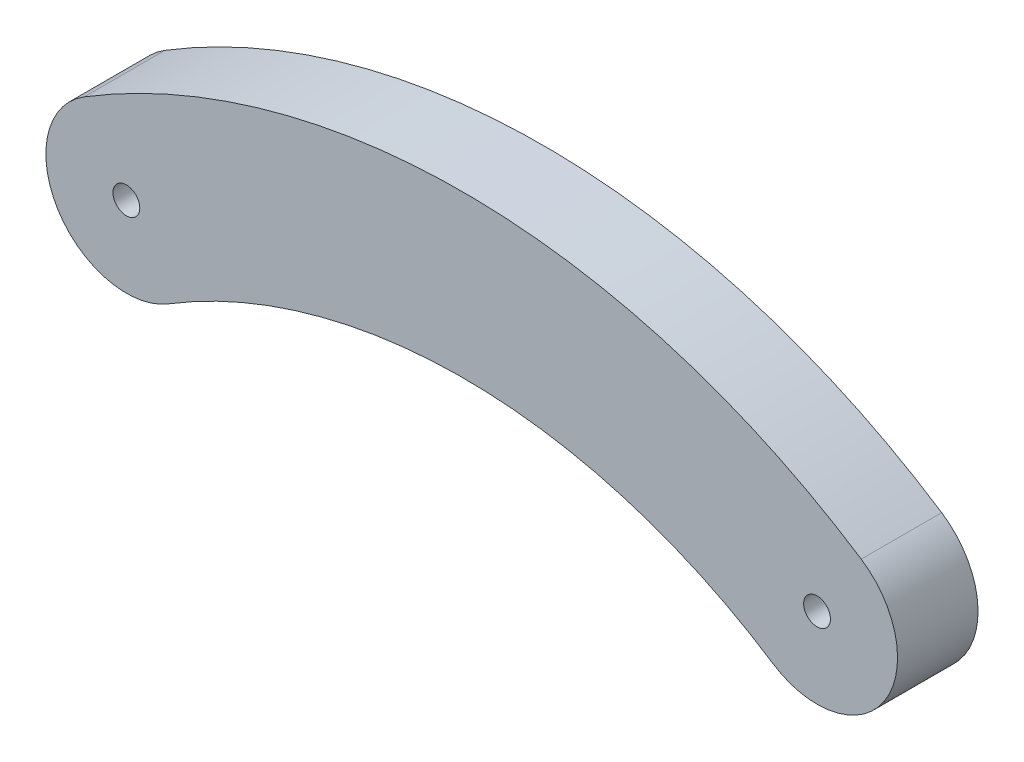
from build123d import *

# Parameters (mm, degrees)
SKETCH1_R           = 0.5
BOSS_EXTRUDE1_DEPTH = 3


with BuildPart() as part:
    # Sketch1 → Boss-Extrude1 (new body)
    with BuildSketch(Plane.XY):
        with BuildLine():
            ThreePointArc((16.667258487, 3.092264578), (2.252499278, 7.520108125), (-12.291231068, 3.536267122))
            ThreePointArc((-12.291231068, 3.536267122), (-13.280504589, -0.589425292), (-9.154812174, -1.578698813))
            ThreePointArc((-9.154812174, -1.578698813), (2.160515814, 1.520813246), (13.375501545, -1.924142128))
            ThreePointArc((13.375501545, -1.924142128), (17.529583369, -1.061817246), (16.667258487, 3.092264578))
        make_face()
        with Locations((-10.723021621, 0.978784155)):
            Circle(SKETCH1_R, mode=Mode.SUBTRACT)
        with Locations((15.021380016, 0.584061225)):
            Circle(SKETCH1_R, mode=Mode.SUBTRACT)
    extrude(amount=BOSS_EXTRUDE1_DEPTH)


solid = part.part
